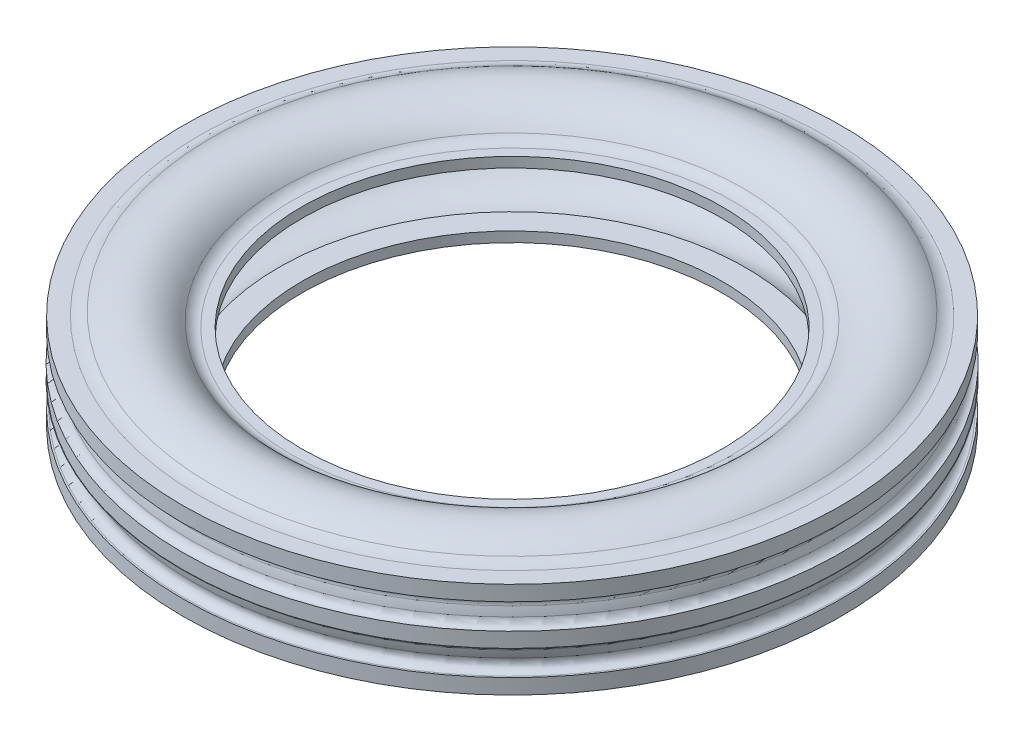
from build123d import *


with BuildPart() as part:
    # Sketch5 → Revolve2 (revolve)
    with BuildSketch(Plane(origin=(0, 433528.712964682, 0), x_dir=(-1, 0, 0), z_dir=(0, 0, -1))):
        with BuildLine():
            Line((-231.33939444, -433501.712964682), (-208, -433501.712964682))
            Line((-208, -433501.712964682), (-208, -433491.712964682))
            Line((-208, -433491.712964682), (-218.040016013, -433491.712964682))
            ThreePointArc((-218.040016013, -433491.712964682), (-224.102193839, -433490.332394146), (-228.96876251, -433486.462964682))
            ThreePointArc((-228.96876251, -433486.462964682), (-261.415066789, -433468.148474826), (-297.51780853, -433477.355821824))
            ThreePointArc((-297.51780853, -433477.355821824), (-303.114341908, -433480.224239532), (-309.324931942, -433481.212964682))
            Line((-309.324931942, -433481.212964682), (-326, -433481.212964682))
            Line((-326, -433481.212964682), (-326, -433496.212964682))
            Line((-326, -433496.212964682), (-324.39560936, -433496.212964682))
            ThreePointArc((-324.39560936, -433496.212964682), (-318.037147664, -433499.358078715), (-316.678212427, -433506.320482929))
            ThreePointArc((-316.678212427, -433506.320482929), (-317.687027604, -433510.410914239), (-318.491925053, -433514.546307383))
            ThreePointArc((-318.491925053, -433514.546307383), (-321.216050894, -433519.32307109), (-326.380024192, -433521.212964682))
            Line((-326.380024192, -433521.212964682), (-326, -433521.212964682))
            Line((-326, -433521.212964682), (-326, -433536.212964682))
            Line((-326, -433536.212964682), (-326.380024192, -433536.212964682))
            ThreePointArc((-326.380024192, -433536.212964682), (-321.216053475, -433538.102861326), (-318.491925053, -433542.87962198))
            ThreePointArc((-318.491925053, -433542.87962198), (-317.687027604, -433547.015015125), (-316.678212427, -433551.105446434))
            ThreePointArc((-316.678212427, -433551.105446434), (-318.037147664, -433558.067850648), (-324.39560936, -433561.212964682))
            Line((-324.39560936, -433561.212964682), (-326, -433561.212964682))
            Line((-326, -433561.212964682), (-326, -433576.212964682))
            Line((-326, -433576.212964682), (-309.324931942, -433576.212964682))
            ThreePointArc((-309.324931942, -433576.212964682), (-303.114341908, -433577.201689831), (-297.51780853, -433580.070107539))
            ThreePointArc((-297.51780853, -433580.070107539), (-261.415066789, -433589.277454537), (-228.96876251, -433570.962964682))
            ThreePointArc((-228.96876251, -433570.962964682), (-224.102193839, -433567.093535217), (-218.040016013, -433565.712964682))
            Line((-218.040016013, -433565.712964682), (-208, -433565.712964682))
            Line((-208, -433565.712964682), (-208, -433555.712964682))
            Line((-208, -433555.712964682), (-231.33939444, -433555.712964682))
            ThreePointArc((-231.33939444, -433555.712964682), (-271.788361055, -433579.533164587), (-307.019994874, -433548.512964682))
            ThreePointArc((-307.019994874, -433548.512964682), (-309.680793884, -433528.712964682), (-307.019994874, -433508.912964682))
            ThreePointArc((-307.019994874, -433508.912964682), (-271.788361055, -433477.892764776), (-231.33939444, -433501.712964682))
        make_face()
    revolve(axis=Axis((0, -31, 0), (0, 1, 0)))


solid = part.part
